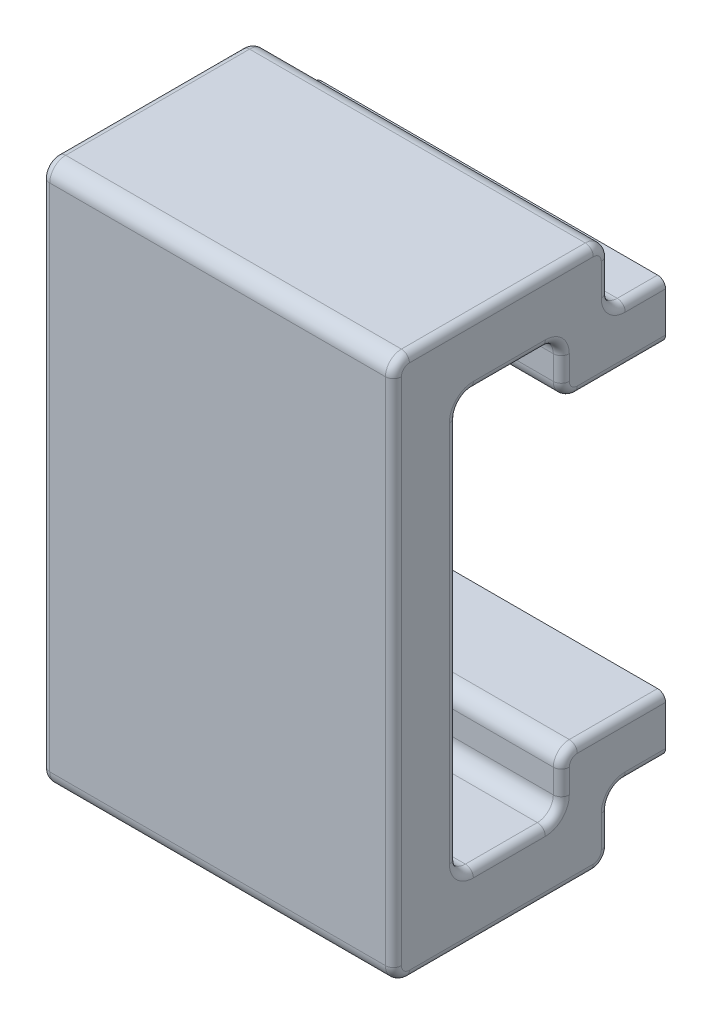
from build123d import *

# Parameters (mm, degrees)
BOSS_EXTRUDE1_DEPTH = 22
FILLET1_R           = 0.5
FILLET2_R           = 0.5
SKETCH11_W          = 18
SKETCH11_H          = 1.3
CUT_EXTRUDE1_DEPTH  = 2.1


with BuildPart() as part:
    # Sketch1 → Boss-Extrude1 (new body)
    with BuildSketch(Plane(origin=(0, 0, 0), x_dir=(0, 0, -1), z_dir=(1, 0, 0))):
        with BuildLine():
            Line((2.084848456, 11.95), (2.084848456, -11.95))
            ThreePointArc((2.084848456, -11.95), (2.377741675, -12.657106781), (3.084848456, -12.95))
            Line((3.084848456, -12.95), (7.584848456, -12.95))
            ThreePointArc((7.584848456, -12.95), (8.291955238, -12.657106781), (8.584848456, -11.95))
            Line((8.584848456, -11.95), (8.584848456, -10.45))
            ThreePointArc((8.584848456, -10.45), (8.877741675, -9.742893219), (9.584848456, -9.45))
            Line((9.584848456, -9.45), (15.107145496, -9.45))
            Line((15.107145496, -9.45), (15.107145496, -12.95))
            Line((15.107145496, -12.95), (12.584848456, -12.95))
            ThreePointArc((12.584848456, -12.95), (11.877741675, -13.242893219), (11.584848456, -13.95))
            Line((11.584848456, -13.95), (11.584848456, -15.95))
            ThreePointArc((11.584848456, -15.95), (11.291955238, -16.657106781), (10.584848456, -16.95))
            Line((10.584848456, -16.95), (0, -16.95))
            Line((0, -16.95), (-0.915151544, -16.95))
            ThreePointArc((-0.915151544, -16.95), (-1.622258325, -16.657106781), (-1.915151544, -15.95))
            Line((-1.915151544, -15.95), (-1.915151544, 15.95))
            ThreePointArc((-1.915151544, 15.95), (-1.622258325, 16.657106781), (-0.915151544, 16.95))
            Line((-0.915151544, 16.95), (0, 16.95))
            Line((0, 16.95), (10.584848456, 16.95))
            ThreePointArc((10.584848456, 16.95), (11.291955238, 16.657106781), (11.584848456, 15.95))
            Line((11.584848456, 15.95), (11.584848456, 13.95))
            ThreePointArc((11.584848456, 13.95), (11.877741675, 13.242893219), (12.584848456, 12.95))
            Line((12.584848456, 12.95), (15.107145496, 12.95))
            Line((15.107145496, 12.95), (15.107145496, 9.45))
            Line((15.107145496, 9.45), (9.584848456, 9.45))
            ThreePointArc((9.584848456, 9.45), (8.877741675, 9.742893219), (8.584848456, 10.45))
            Line((8.584848456, 10.45), (8.584848456, 11.95))
            ThreePointArc((8.584848456, 11.95), (8.291955238, 12.657106781), (7.584848456, 12.95))
            Line((7.584848456, 12.95), (3.084848456, 12.95))
            ThreePointArc((3.084848456, 12.95), (2.377741675, 12.657106781), (2.084848456, 11.95))
        make_face()
    extrude(amount=BOSS_EXTRUDE1_DEPTH)

    # Fillet1
    fillet1_edges = [part.edges().sort_by_distance(p)[0] for p in [
        (22, 13.242893219, -11.877741675),
        (22, 14.95, -11.584848456),
        (22, 16.657106781, -11.291955238),
        (22, 16.95, -4.834848456),
        (22, 16.657106781, 1.622258325),
        (22, 0, 1.915151544),
        (22, -16.657106781, 1.622258325),
        (22, -16.95, -4.834848456),
        (22, -16.657106781, -11.291955238),
        (22, -14.95, -11.584848456),
        (22, -13.242893219, -11.877741675),
        (22, -12.95, -13.845996976),
        (22, -9.45, -12.345996976),
        (22, -9.742893219, -8.877741675),
        (22, -11.2, -8.584848456),
        (22, -12.657106781, -8.291955238),
        (22, -12.95, -5.334848456),
        (22, 12.95, -13.845996976),
        (22, -12.657106781, -2.377741675),
        (22, 0, -2.084848456),
        (22, 12.657106781, -2.377741675),
        (22, 12.95, -5.334848456),
        (22, 12.657106781, -8.291955238),
        (22, 11.2, -8.584848456),
        (22, 9.742893219, -8.877741675),
        (22, 9.45, -12.345996976),
    ]]
    fillet(fillet1_edges, radius=FILLET1_R)

    # Fillet2
    fillet2_edges = [part.edges().sort_by_distance(p)[0] for p in [
        (0, 9.45, -12.345996976),
        (0, 9.742893219, -8.877741675),
        (0, 11.2, -8.584848456),
        (0, 12.657106781, -8.291955238),
        (0, 12.95, -5.334848456),
        (0, 12.657106781, -2.377741675),
        (0, 0, -2.084848456),
        (0, -12.657106781, -2.377741675),
        (0, -12.95, -5.334848456),
        (0, -12.657106781, -8.291955238),
        (0, -11.2, -8.584848456),
        (0, -9.742893219, -8.877741675),
        (0, -9.45, -12.345996976),
        (0, -12.95, -13.845996976),
        (0, -13.242893219, -11.877741675),
        (0, -14.95, -11.584848456),
        (0, -16.657106781, -11.291955238),
        (0, -16.95, -4.834848456),
        (0, -16.657106781, 1.622258325),
        (0, 0, 1.915151544),
        (0, 16.657106781, 1.622258325),
        (0, 16.95, -4.834848456),
        (0, 16.657106781, -11.291955238),
        (0, 14.95, -11.584848456),
        (0, 13.242893219, -11.877741675),
        (0, 12.95, -13.845996976),
    ]]
    fillet(fillet2_edges, radius=FILLET2_R)

    # Sketch11 → Cut-Extrude1 (cut)
    with BuildSketch(Plane(origin=(0, 0, -15.107145496), x_dir=(-1, 0, 0), z_dir=(0, 0, -1))):
        with Locations((-11, 11.2)):
            Rectangle(SKETCH11_W, SKETCH11_H)
        with Locations((-11, -11.2)):
            Rectangle(SKETCH11_W, SKETCH11_H)
    extrude(amount=-CUT_EXTRUDE1_DEPTH, mode=Mode.SUBTRACT)


solid = part.part
